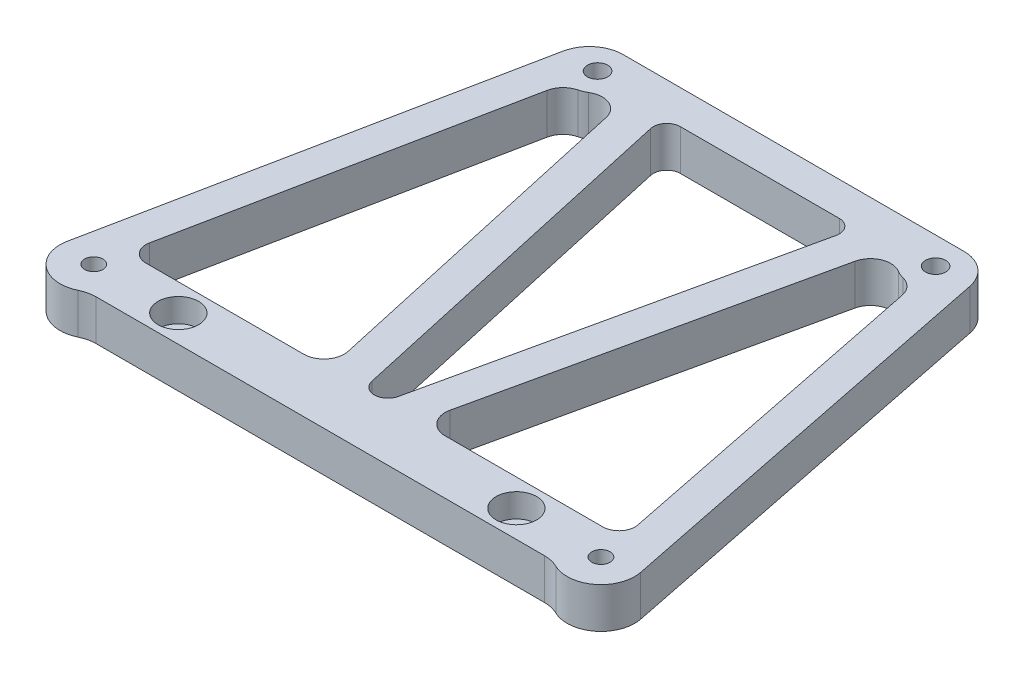
from build123d import *

# Parameters (mm, degrees)
SKETCH_2_R          = 1.5
SKETCH_2_R_2        = 1.35
EXTRUDE_1_DEPTH     = 6
SKETCH_5_R          = 3
CUT_EXTRUDE_4_DEPTH = 3.5
CUT_EXTRUDE_5_DEPTH = 4
CUT_EXTRUDE_6_DEPTH = 7


with BuildPart() as part:
    # 草图2 → 凸台-拉伸1 (new body)
    with BuildSketch(Plane(origin=(0, 0, 0), x_dir=(1, 0, 0), z_dir=(0, 1, 0))):
        with BuildLine():
            Line((-42.5, -62), (-42.5, 1))
            ThreePointArc((-42.5, 1), (-41.621320344, 3.121320344), (-39.5, 4))
            Line((-39.5, 4), (39.5, 4))
            ThreePointArc((39.5, 4), (41.621320344, 3.121320344), (42.5, 1))
            Line((42.5, 1), (42.5, -62))
            ThreePointArc((42.5, -62), (40.155442773, -66.236581603), (35.320550528, -66.5))
            ThreePointArc((35.320550528, -66.5), (34.259135045, -66.126602828), (33.141101056, -66))
            Line((33.141101056, -66), (-33.141101056, -66))
            ThreePointArc((-33.141101056, -66), (-34.259135045, -66.126602828), (-35.320550528, -66.5))
            ThreePointArc((-35.320550528, -66.5), (-40.155442773, -66.236581603), (-42.5, -62))
        make_face()
        with Locations((-25, 0)):
            Circle(SKETCH_2_R, mode=Mode.SUBTRACT)
        with Locations((25, 0)):
            Circle(SKETCH_2_R, mode=Mode.SUBTRACT)
        with Locations((-25, -62)):
            Circle(SKETCH_2_R, mode=Mode.SUBTRACT)
        with Locations((25, -62)):
            Circle(SKETCH_2_R, mode=Mode.SUBTRACT)
        with Locations((-37.5, -62)):
            Circle(SKETCH_2_R_2, mode=Mode.SUBTRACT)
        with Locations((37.5, -62)):
            Circle(SKETCH_2_R_2, mode=Mode.SUBTRACT)
    extrude(amount=EXTRUDE_1_DEPTH)

    # 草图5 → 切除-拉伸4 (cut)
    with BuildSketch(Plane(origin=(0, 6, 0), x_dir=(1, 0, 0), z_dir=(0, 1, 0))):
        with Locations((-25, -62)):
            Circle(SKETCH_5_R)
        with Locations((25, -62)):
            Circle(SKETCH_5_R)
    extrude(amount=-CUT_EXTRUDE_4_DEPTH, mode=Mode.SUBTRACT)

    # 草图6 → 切除-拉伸5 (cut)
    with BuildSketch(Plane.XZ):
        Polygon((-36.027756814, 64.55), (-38.972243186, 64.55), (-40.444486373, 62), (-38.972243186, 59.45), (-36.027756814, 59.45), (-34.555513627, 62), align=None)
        Polygon((34.555513627, 62), (36.027756814, 64.55), (38.972243186, 64.55), (40.444486373, 62), (38.972243186, 59.45), (36.027756814, 59.45), align=None)
    extrude(amount=-CUT_EXTRUDE_5_DEPTH, mode=Mode.SUBTRACT)

    # 草图7 → 切除-拉伸6 (cut, through all)
    with BuildSketch(Plane(origin=(0, 6, 0), x_dir=(1, 0, 0), z_dir=(0, 1, 0))):
        with BuildLine():
            Line((-33.791892668, -58), (-10.464489806, -58))
            ThreePointArc((-10.464489806, -58), (-8.124836357, -56.877770417), (-7.535601784, -54.350681158))
            Line((-7.535601784, -54.350681158), (-18.406585082, -5.314844354))
            ThreePointArc((-18.406585082, -5.314844354), (-20.164908448, -3.201957847), (-22.905984631, -3.408093255))
            ThreePointArc((-22.905984631, -3.408093255), (-23.45168362, -3.688186057), (-24.033791208, -3.88155131))
            ThreePointArc((-24.033791208, -3.88155131), (-25.477663554, -4.719677831), (-26.249960939, -6.199806259))
            Line((-26.249960939, -6.199806259), (-36.120076242, -55.155578159))
            ThreePointArc((-36.120076242, -55.155578159), (-35.629770137, -57.129288416), (-33.791892668, -58))
        make_face()
        with BuildLine():
            Line((-13.702409134, -3.432879228), (-1.952592014, -56.432879228))
            ThreePointArc((-1.952592014, -56.432879228), (0, -58), (1.952592014, -56.432879228))
            Line((1.952592014, -56.432879228), (13.702409134, -3.432879228))
            ThreePointArc((13.702409134, -3.432879228), (13.309586086, -1.748153056), (11.74981712, -1))
            Line((11.74981712, -1), (-11.74981712, -1))
            ThreePointArc((-11.74981712, -1), (-13.309586086, -1.748153056), (-13.702409134, -3.432879228))
        make_face()
        with BuildLine():
            Line((18.406585082, -5.314844354), (7.535601784, -54.350681158))
            ThreePointArc((7.535601784, -54.350681158), (8.124836357, -56.877770417), (10.464489806, -58))
            Line((10.464489806, -58), (33.791892668, -58))
            ThreePointArc((33.791892668, -58), (35.629770137, -57.129288416), (36.120076242, -55.155578159))
            Line((36.120076242, -55.155578159), (26.249960939, -6.199806259))
            ThreePointArc((26.249960939, -6.199806259), (25.477663554, -4.719677831), (24.033791208, -3.88155131))
            ThreePointArc((24.033791208, -3.88155131), (23.45168362, -3.688186057), (22.905984631, -3.408093255))
            ThreePointArc((22.905984631, -3.408093255), (20.164908448, -3.201957847), (18.406585082, -5.314844354))
        make_face()
        with BuildLine():
            Line((-42.401377208, -61.011819111), (-30.102990111, -0.011819111))
            ThreePointArc((-30.102990111, -0.011819111), (-28.368559031, 2.869166864), (-25.201612903, 4))
            Line((-25.201612903, 4), (-42.5, 4))
            Line((-42.5, 4), (-42.5, -62))
            ThreePointArc((-42.5, -62), (-42.47528321, -61.503454956), (-42.401377208, -61.011819111))
        make_face()
        with BuildLine():
            Line((42.401377208, -61.011819111), (30.102990111, -0.011819111))
            ThreePointArc((30.102990111, -0.011819111), (28.368559031, 2.869166864), (25.201612903, 4))
            Line((25.201612903, 4), (42.5, 4))
            Line((42.5, 4), (42.5, -62))
            ThreePointArc((42.5, -62), (42.47528321, -61.503454956), (42.401377208, -61.011819111))
        make_face()
    extrude(amount=-CUT_EXTRUDE_6_DEPTH, mode=Mode.SUBTRACT)


solid = part.part
